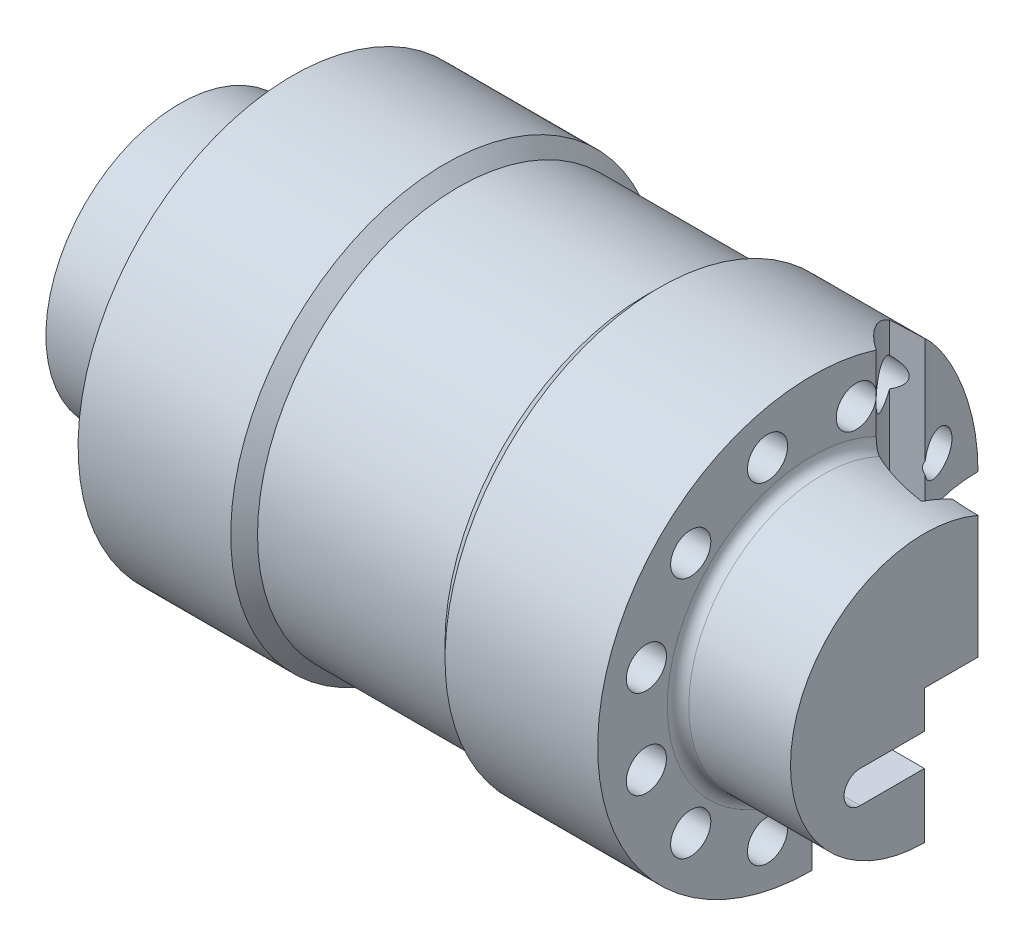
from build123d import *

# Parameters (mm, degrees)
SKETCH2_W               = 86.249778207
SKETCH2_H               = 59.255694893
CUT_EXTRUDE1_DEPTH      = 1
CUT_EXTRUDE1_DEPTH_BACK = 139
CUT_EXTRUDE2_REACH      = 42
SKETCH4_R               = 3.75
CUT_EXTRUDE3_DEPTH      = 139
CUT_EXTRUDE4_DEPTH      = 10
FILLET1_R               = 1


with BuildPart() as part:
    # Sketch1 → Revolve1 (revolve)
    with BuildSketch(Plane(origin=(0, 0, 0), x_dir=(1, 0, 0), z_dir=(0, 1, 0))):
        with BuildLine():
            Line((-71.076656526, -28.85165756), (-71.076656526, -3.85165756))
            Line((-71.076656526, -3.85165756), (-52.076656526, -3.85165756))
            ThreePointArc((-52.076656526, -3.85165756), (-50.662442964, -3.265871122), (-50.076656526, -1.85165756))
            Line((-50.076656526, -1.85165756), (-50.076656526, 11.14834244))
            Line((-50.076656526, 11.14834244), (-21.576656526, 11.14834244))
            Line((-21.576656526, 11.14834244), (-19.076656526, 8.64834244))
            Line((-19.076656526, 8.64834244), (-1.576656526, 8.64834244))
            Line((-1.576656526, 8.64834244), (-1.576656526, -28.85165756))
            Line((-1.576656526, -28.85165756), (-71.076656526, -28.85165756))
        make_face()
    revolve1 = revolve(axis=Axis((-71.076656526, 0, 28.85165756), (1, 0, 0)))

    # Mirror6: Revolve1 across plane
    add(revolve1.mirror(Plane(origin=(-1.576656526, 0, 28.85165756), x_dir=(0, 0, 1), z_dir=(-1, 0, 0))))

    # Sketch2 → Cut-Extrude1 (cut, two sides)
    with BuildSketch(Plane.ZY.offset(71.076656526)) as cut_extrude1_sk:
        with Locations((-14.273231544, -29.627847447)):
            Rectangle(SKETCH2_W, SKETCH2_H)
        with BuildLine():
            Line((40.85165756, -13), (15.970307324, -13))
            ThreePointArc((15.970307324, -13), (12.970307324, -10), (15.970307324, -7))
            Line((15.970307324, -7), (40.85165756, -7))
            ThreePointArc((40.85165756, -7), (43.85165756, -10), (40.85165756, -13))
        make_face()
    extrude(amount=CUT_EXTRUDE1_DEPTH, mode=Mode.SUBTRACT)
    extrude(cut_extrude1_sk.sketch, amount=-CUT_EXTRUDE1_DEPTH_BACK, mode=Mode.SUBTRACT)

    # Sketch3 → Cut-Extrude2 (cut, up to next)
    with BuildSketch(Plane.XZ, mode=Mode.PRIVATE) as cut_extrude2_sk1:
        with BuildLine():
            ThreePointArc((61.845657255, 23.319928915), (46.616693458, 16.61902447), (36.202570927, 3.643296721))
            Line((36.202570927, 3.643296721), (40.734109863, 1.530205412))
            ThreePointArc((40.734109863, 1.530205412), (38.63446326, -4.655154022), (37.923343474, -11.14834244))
            Line((37.923343474, -11.14834244), (46.923343474, -11.14834244))
            Line((46.923343474, -11.14834244), (46.923343474, 1.85165756))
            ThreePointArc((46.923343474, 1.85165756), (47.509129911, 3.265871122), (48.923343474, 3.85165756))
            Line((48.923343474, 3.85165756), (67.923343474, 3.85165756))
            Line((67.923343474, 3.85165756), (67.923343474, 18.85165756))
            ThreePointArc((67.923343474, 18.85165756), (65.308671191, 18.737498502), (62.713898144, 18.39589015))
            Line((62.713898144, 18.39589015), (61.845657255, 23.319928915))
        make_face()
    cut_extrude2_tool1 = extrude(cut_extrude2_sk1.sketch, amount=-CUT_EXTRUDE2_REACH, mode=Mode.PRIVATE) & part.part
    add(cut_extrude2_tool1.solids().sort_by_distance((52.095068, 0, 8.03678))[0], mode=Mode.SUBTRACT)

    # Sketch4 → Cut-Extrude3 (cut)
    with BuildSketch(Plane.ZY.offset(71.076656526)):
        with Locations((20.569448116, 30.909626441)):
            Circle(SKETCH4_R)
        with Locations((37.133867003, 30.909626441)):
            Circle(SKETCH4_R)
        with Locations((51.479074558, 22.627416998)):
            Circle(SKETCH4_R)
        with Locations((59.761284001, 8.282209443)):
            Circle(SKETCH4_R)
        with Locations((59.761284001, -8.282209443)):
            Circle(SKETCH4_R)
        with Locations((51.479074558, -22.627416998)):
            Circle(SKETCH4_R)
        with Locations((37.133867003, -30.909626441)):
            Circle(SKETCH4_R)
        with Locations((20.569448116, -30.909626441)):
            Circle(SKETCH4_R)
        with Locations((6.224240562, -22.627416998)):
            Circle(SKETCH4_R)
        with Locations((-2.057968882, -8.282209443)):
            Circle(SKETCH4_R)
        with Locations((-2.057968882, 8.282209443)):
            Circle(SKETCH4_R)
        with Locations((6.224240562, 22.627416998)):
            Circle(SKETCH4_R)
    extrude(amount=-CUT_EXTRUDE3_DEPTH, mode=Mode.SUBTRACT)

    # Sketch6 → Cut-Extrude4 (cut)
    with BuildSketch(Plane.ZY.offset(71.076656526)):
        with BuildLine():
            Line((32.85165756, 4), (32.85165756, -3))
            Line((32.85165756, -3), (40.85165756, -3))
            Line((40.85165756, -3), (49.63626725, -3))
            ThreePointArc((49.63626725, -3), (32.352678431, 20.706106656), (8.236129431, 4))
            Line((8.236129431, 4), (32.85165756, 4))
        make_face()
    extrude(amount=-CUT_EXTRUDE4_DEPTH, mode=Mode.SUBTRACT)

    # Fillet1
    fillet1_edges = [part.edges().sort_by_distance(p)[0] for p in [
        (-61.076656526, -3, 41.243962405),
        (-61.076656526, 0.5, 32.85165756),
        (-61.076656526, 4, 20.543893496),
        (-61.076656526, 20.706106656, 32.352678431),
        (-71.076656526, -3, 41.243962405),
        (-71.076656526, 20.706106656, 32.352678431),
        (-71.076656526, 4, 20.543893496),
        (-71.076656526, 0.5, 32.85165756),
    ]]
    fillet(fillet1_edges, radius=FILLET1_R)


solid = part.part
